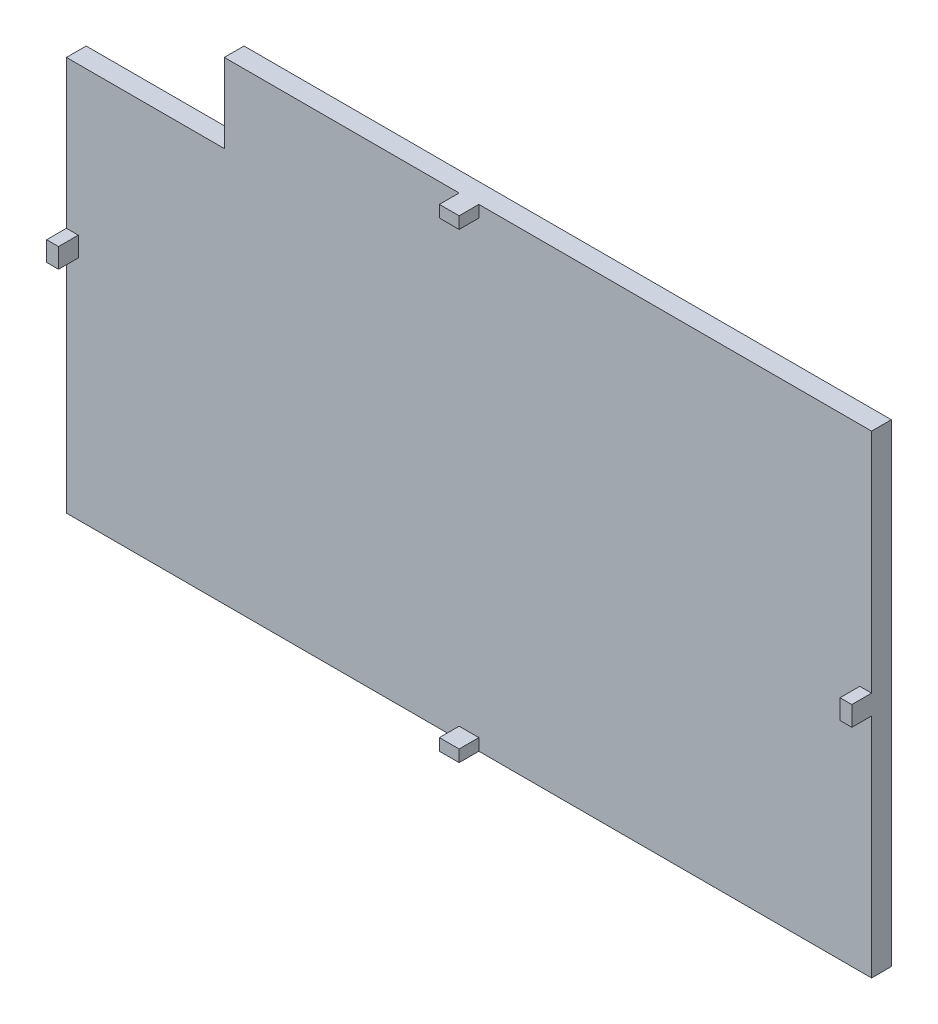
from build123d import *

# Parameters (mm, degrees)
ESBO_O1_W                = 204
ESBO_O1_H                = 120
RESSALTO_EXTRUS_O1_DEPTH = 5
ESBO_O2_W                = 5
ESBO_O2_H                = 3
ESBO_O2_W_2              = 3
ESBO_O2_H_2              = 5
RESSALTO_EXTRUS_O2_DEPTH = 5
ESBO_O3_W                = 40
ESBO_O3_H                = 20
CORTE_EXTRUS_O1_DEPTH    = 10


with BuildPart() as part:
    # Esboço1 → Ressalto-extrusão1 (new body)
    with BuildSketch(Plane.XY):
        with Locations((50.579294312, -29.131049069)):
            Rectangle(ESBO_O1_W, ESBO_O1_H)
    extrude(amount=RESSALTO_EXTRUS_O1_DEPTH)

    # Esboço2 → Ressalto-extrusão2 (add)
    with BuildSketch(Plane.XY.offset(5)):
        with Locations((50.579294312, 29.368950931)):
            Rectangle(ESBO_O2_W, ESBO_O2_H)
        with Locations((50.579294312, -87.631049069)):
            Rectangle(ESBO_O2_W, ESBO_O2_H)
        with Locations((-49.920705688, -29.131049069)):
            Rectangle(ESBO_O2_W_2, ESBO_O2_H_2)
        with Locations((151.079294312, -29.131049069)):
            Rectangle(ESBO_O2_W_2, ESBO_O2_H_2)
    extrude(amount=RESSALTO_EXTRUS_O2_DEPTH)

    # Esboço3 → Corte-extrusão1 (cut)
    with BuildSketch(Plane(origin=(0, 0, 0), x_dir=(-1, 0, 0), z_dir=(0, 0, -1))):
        with Locations((31.420705688, 20.868950931)):
            Rectangle(ESBO_O3_W, ESBO_O3_H)
    extrude(amount=-CORTE_EXTRUS_O1_DEPTH, mode=Mode.SUBTRACT)


solid = part.part
